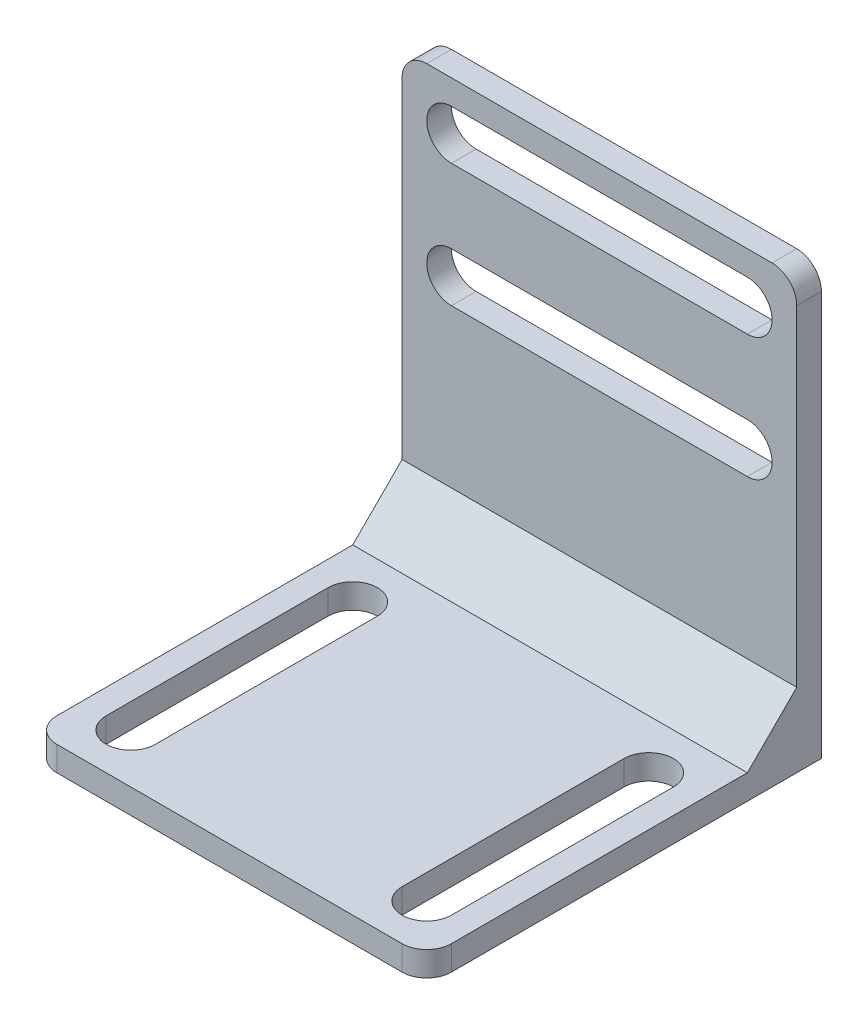
from build123d import *

# Parameters (mm, degrees)
SKETCH1_W           = 80
SKETCH1_H           = 80
BOSS_EXTRUDE1_DEPTH = 5
SKETCH2_W           = 80
SKETCH2_H           = 5
BOSS_EXTRUDE2_DEPTH = 82
CUT_EXTRUDE1_DEPTH  = 81
CUT_EXTRUDE2_DEPTH  = 6
FILLET1_R           = 5
FILLET2_R           = 5
BOSS_EXTRUDE3_DEPTH = 80


with BuildPart() as part:
    # Sketch1 → Boss-Extrude1 (new body)
    with BuildSketch(Plane(origin=(0, 0, 0), x_dir=(1, 0, 0), z_dir=(0, 1, 0))):
        Rectangle(SKETCH1_W, SKETCH1_H)
    extrude(amount=BOSS_EXTRUDE1_DEPTH)

    # Sketch2 → Boss-Extrude2 (add)
    with BuildSketch(Plane(origin=(0, 5, 0), x_dir=(1, 0, 0), z_dir=(0, 1, 0))):
        with Locations((0, 37.5)):
            Rectangle(SKETCH2_W, SKETCH2_H)
    extrude(amount=BOSS_EXTRUDE2_DEPTH)

    # Sketch6 → Cut-Extrude1 (cut, through all)
    with BuildSketch(Plane(origin=(0, 0, -40), x_dir=(-1, 0, 0), z_dir=(0, 0, -1))):
        with BuildLine():
            Line((-30, 82), (30, 82))
            ThreePointArc((30, 82), (35, 77), (30, 72))
            Line((30, 72), (-30, 72))
            ThreePointArc((-30, 72), (-35, 77), (-30, 82))
        make_face()
        with BuildLine():
            Line((-30, 57), (30, 57))
            ThreePointArc((30, 57), (35, 52), (30, 47))
            Line((30, 47), (-30, 47))
            ThreePointArc((-30, 47), (-35, 52), (-30, 57))
        make_face()
    extrude(amount=-CUT_EXTRUDE1_DEPTH, mode=Mode.SUBTRACT)

    # Sketch7 → Cut-Extrude2 (cut, through all)
    with BuildSketch(Plane(origin=(0, 5, 0), x_dir=(1, 0, 0), z_dir=(0, 1, 0))):
        with BuildLine():
            Line((-35, -30), (-35, 15))
            ThreePointArc((-35, 15), (-30, 20), (-25, 15))
            Line((-25, 15), (-25, -30))
            ThreePointArc((-25, -30), (-30, -35), (-35, -30))
        make_face()
        with BuildLine():
            Line((35, 15), (35, -30))
            ThreePointArc((35, -30), (30, -35), (25, -30))
            Line((25, -30), (25, 15))
            ThreePointArc((25, 15), (30, 20), (35, 15))
        make_face()
    extrude(amount=-CUT_EXTRUDE2_DEPTH, mode=Mode.SUBTRACT)

    # Fillet1
    fillet1_edges = [part.edges().sort_by_distance(p)[0] for p in [
        (40, 2.5, 40),
        (-40, 2.5, 40),
    ]]
    fillet(fillet1_edges, radius=FILLET1_R)

    # Fillet2
    fillet2_edges = [part.edges().sort_by_distance(p)[0] for p in [
        (-40, 87, -37.5),
        (40, 87, -37.5),
    ]]
    fillet(fillet2_edges, radius=FILLET2_R)

    # Sketch8 → Boss-Extrude3 (add)
    with BuildSketch(Plane(origin=(40, 0, 0), x_dir=(0, 0, -1), z_dir=(1, 0, 0))):
        Polygon((35, 15), (25, 5), (35, 5), align=None)
    extrude(amount=-BOSS_EXTRUDE3_DEPTH)


solid = part.part
